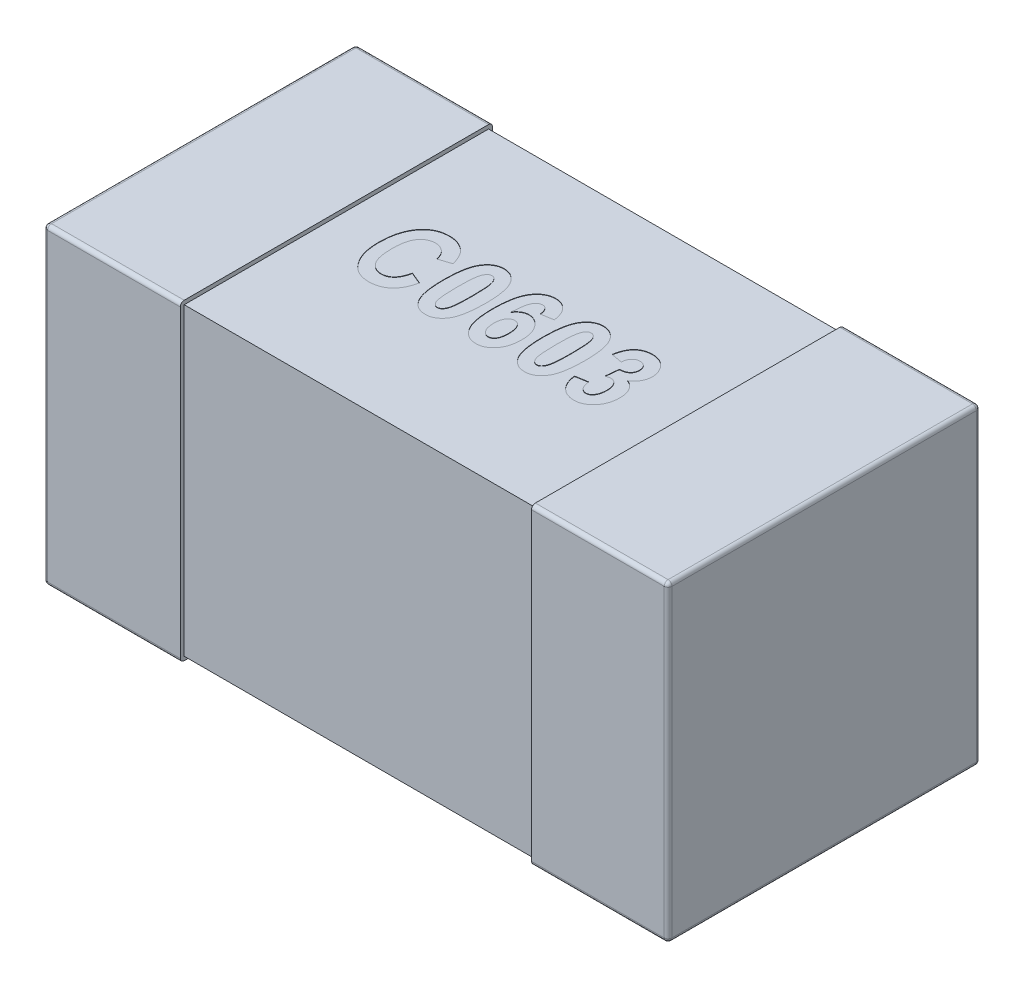
from build123d import *

# Parameters (mm, degrees)
SKETCH1_W            = 0.35
SKETCH1_H            = 0.8
THICKNESS_DEPTH      = 0.8
FILLET1_R            = 0.01
SKETCH2_W            = 0.78
SKETCH2_H            = 0.78
BOSS_EXTRUDE2_DEPTH  = 0.45
FILLET1_OF_MIRROR3_R = 0.01
CUT_EXTRUDE1_DEPTH   = 0.001


with BuildPart() as part:
    # Sketch1 → THICKNESS (new body)
    with BuildSketch(Plane(origin=(0, 0, 0), x_dir=(1, 0, 0), z_dir=(0, 1, 0))):
        with Locations((-0.625, 0)):
            Rectangle(SKETCH1_W, SKETCH1_H)
    thickness = extrude(amount=THICKNESS_DEPTH)

    # Fillet1
    fillet1_edges = [part.edges().sort_by_distance(p)[0] for p in [
        (-0.625, 0.8, -0.4),
        (-0.8, 0.8, 0),
        (-0.625, 0, -0.4),
        (-0.625, 0, 0.4),
        (-0.8, 0, 0),
        (-0.625, 0.8, 0.4),
        (-0.8, 0.4, -0.4),
        (-0.8, 0.4, 0.4),
    ]]
    fillet(fillet1_edges, radius=FILLET1_R)

    # Sketch2 → Boss-Extrude2 (add)
    with BuildSketch(Plane(origin=(0, 0, 0), x_dir=(0, 0, -1), z_dir=(1, 0, 0))):
        with Locations((0, 0.4)):
            Rectangle(SKETCH2_W, SKETCH2_H)
    boss_extrude2 = extrude(amount=-BOSS_EXTRUDE2_DEPTH)

    # Mirror3: THICKNESS, Boss-Extrude2 across plane
    add(thickness.mirror(Plane(origin=(0, 0, 0), x_dir=(0, 0, 1), z_dir=(1, 0, 0))))
    add(boss_extrude2.mirror(Plane(origin=(0, 0, 0), x_dir=(0, 0, 1), z_dir=(1, 0, 0))))

    # Fillet1 of Mirror3
    fillet1_of_mirror3_edges = [part.edges().sort_by_distance(p)[0] for p in [
        (0.625, 0.8, -0.4),
        (0.8, 0.8, 0),
        (0.625, 0, -0.4),
        (0.625, 0, 0.4),
        (0.8, 0, 0),
        (0.625, 0.8, 0.4),
        (0.8, 0.4, -0.4),
        (0.8, 0.4, 0.4),
    ]]
    fillet(fillet1_of_mirror3_edges, radius=FILLET1_OF_MIRROR3_R)

    # Sketch3 → Cut-Extrude1 (cut)
    with BuildSketch(Plane(origin=(0, 0.79, 0), x_dir=(1, 0, 0), z_dir=(0, 1, 0))):
        with BuildLine():
            Line((-0.227922078, -0.027272727), (-0.196753247, -0.04025974))
            add(Edge.make_bspline(
                [(-0.196753247, -0.04025974), (-0.197396972, -0.042879768), (-0.198651302, -0.04798502), (-0.201024323, -0.055281862), (-0.20363556, -0.062052219), (-0.206622963, -0.068258196), (-0.209884108, -0.07395424), (-0.213506576, -0.0790843), (-0.217422215, -0.083674642), (-0.221653294, -0.087714541), (-0.226192954, -0.09119055), (-0.230913731, -0.094288028), (-0.23593753, -0.0968273), (-0.241194004, -0.098971324), (-0.246724478, -0.10056505), (-0.252486934, -0.101764395), (-0.258506105, -0.102450716), (-0.262606545, -0.102547957), (-0.264691558, -0.102597403)],
                knots=[0, 0, 0, 0, 8.091e-06, 1.5766e-05, 2.3002e-05, 2.9845e-05, 3.6409e-05, 4.267e-05, 4.8657e-05, 5.4484e-05, 6.0183e-05, 6.5789e-05, 7.1397e-05, 7.7042e-05, 8.2795e-05, 8.8638e-05, 9.4684e-05, 0.000100938, 0.000100938, 0.000100938, 0.000100938], degree=3))
            add(Edge.make_bspline(
                [(-0.264691558, -0.102597403), (-0.267307616, -0.102538587), (-0.27243241, -0.102423369), (-0.27991047, -0.101183652), (-0.287026489, -0.099300118), (-0.293767638, -0.096595352), (-0.300141913, -0.093138085), (-0.306081973, -0.088855751), (-0.311726426, -0.083907776), (-0.315008286, -0.080049813), (-0.316680195, -0.078084416)],
                knots=[0, 0, 0, 0, 7.841e-06, 1.5361e-05, 2.2676e-05, 2.9888e-05, 3.7098e-05, 4.4373e-05, 5.1818e-05, 5.955e-05, 5.955e-05, 5.955e-05, 5.955e-05], degree=3))
            add(Edge.make_bspline(
                [(-0.316680195, -0.078084416), (-0.318517958, -0.075657886), (-0.322220302, -0.070769417), (-0.32686839, -0.062708341), (-0.330821677, -0.054048069), (-0.334057248, -0.044780752), (-0.336579205, -0.034896124), (-0.338342381, -0.024389471), (-0.339401221, -0.013265876), (-0.33953961, -0.005643601), (-0.33961039, -0.00174513)],
                knots=[0, 0, 0, 0, 9.125e-06, 1.8382e-05, 2.7844e-05, 3.765e-05, 4.7789e-05, 5.8411e-05, 6.9581e-05, 8.1275e-05, 8.1275e-05, 8.1275e-05, 8.1275e-05], degree=3))
            add(Edge.make_bspline(
                [(-0.33961039, -0.00174513), (-0.339545727, 0.002370257), (-0.339419775, 0.010386341), (-0.338285771, 0.022056996), (-0.336557029, 0.033059647), (-0.333979548, 0.043353397), (-0.330750684, 0.052997355), (-0.326761432, 0.061931382), (-0.322129511, 0.070248915), (-0.318350392, 0.075216426), (-0.316477273, 0.077678571)],
                knots=[0, 0, 0, 0, 1.2343e-05, 2.4042e-05, 3.5145e-05, 4.5726e-05, 5.5839e-05, 6.5614e-05, 7.5047e-05, 8.4318e-05, 8.4318e-05, 8.4318e-05, 8.4318e-05], degree=3))
            add(Edge.make_bspline(
                [(-0.316477273, 0.077678571), (-0.314776573, 0.079668828), (-0.311424858, 0.083591197), (-0.305695981, 0.088670389), (-0.299541368, 0.092987883), (-0.292963246, 0.096522814), (-0.285932181, 0.099272168), (-0.278482585, 0.101212155), (-0.27058463, 0.102356825), (-0.265182368, 0.102515984), (-0.262418831, 0.102597403)],
                knots=[0, 0, 0, 0, 7.846e-06, 1.5463e-05, 2.2894e-05, 3.0357e-05, 3.7811e-05, 4.5489e-05, 5.3404e-05, 6.1693e-05, 6.1693e-05, 6.1693e-05, 6.1693e-05], degree=3))
            add(Edge.make_bspline(
                [(-0.262418831, 0.102597403), (-0.26015725, 0.102543269), (-0.255712218, 0.102436871), (-0.249194385, 0.10158628), (-0.242984546, 0.100090634), (-0.237022085, 0.098128813), (-0.231359313, 0.095503917), (-0.225979856, 0.092318759), (-0.220862559, 0.088583811), (-0.217760884, 0.085680237), (-0.216193182, 0.084212662)],
                knots=[0, 0, 0, 0, 6.784e-06, 1.3333e-05, 1.9672e-05, 2.5922e-05, 3.2133e-05, 3.8355e-05, 4.4654e-05, 5.1092e-05, 5.1092e-05, 5.1092e-05, 5.1092e-05], degree=3))
            add(Edge.make_bspline(
                [(-0.216193182, 0.084212662), (-0.215103174, 0.083081576), (-0.212882044, 0.080776741), (-0.209891288, 0.076894389), (-0.207122366, 0.072618732), (-0.204624923, 0.067931521), (-0.20230313, 0.062878571), (-0.200191884, 0.057433978), (-0.198334576, 0.051585357), (-0.1972885, 0.04752972), (-0.196753247, 0.045454545)],
                knots=[0, 0, 0, 0, 4.71e-06, 9.597e-06, 1.4674e-05, 1.9976e-05, 2.5515e-05, 3.1348e-05, 3.7483e-05, 4.3912e-05, 4.3912e-05, 4.3912e-05, 4.3912e-05], degree=3))
            Line((-0.196753247, 0.045454545), (-0.227922078, 0.035064935))
            add(Edge.make_bspline(
                [(-0.227922078, 0.035064935), (-0.22821497, 0.03639518), (-0.228784889, 0.038983617), (-0.229929141, 0.042719083), (-0.231322222, 0.046188588), (-0.232837913, 0.049475424), (-0.234663056, 0.052465903), (-0.236572214, 0.055302912), (-0.238810881, 0.057816392), (-0.24117597, 0.060138417), (-0.243750905, 0.062145031), (-0.246386582, 0.0639597), (-0.249161582, 0.065468465), (-0.252064328, 0.066681891), (-0.255060441, 0.06766392), (-0.258172246, 0.068354506), (-0.261392621, 0.068772702), (-0.263580975, 0.068811486), (-0.264691558, 0.068831169)],
                knots=[0, 0, 0, 0, 4.085e-06, 7.949e-06, 1.1703e-05, 1.5297e-05, 1.8791e-05, 2.2202e-05, 2.5539e-05, 2.8868e-05, 3.2133e-05, 3.5318e-05, 3.846e-05, 4.1588e-05, 4.4745e-05, 4.7906e-05, 5.1138e-05, 5.4468e-05, 5.4468e-05, 5.4468e-05, 5.4468e-05], degree=3))
            add(Edge.make_bspline(
                [(-0.264691558, 0.068831169), (-0.26626331, 0.068784568), (-0.269356679, 0.068692853), (-0.27388873, 0.067963151), (-0.278176666, 0.066672511), (-0.282285043, 0.064978155), (-0.286144826, 0.062720768), (-0.289798982, 0.05998704), (-0.293149256, 0.056694357), (-0.296360139, 0.052990654), (-0.299269743, 0.048699448), (-0.301740196, 0.043739955), (-0.303777871, 0.038129881), (-0.305533087, 0.03190946), (-0.306846312, 0.025037823), (-0.30775765, 0.017525613), (-0.308326427, 0.009383722), (-0.308402299, 0.003734743), (-0.308441558, 0.000811688)],
                knots=[0, 0, 0, 0, 4.714e-06, 9.278e-06, 1.3721e-05, 1.8123e-05, 2.2578e-05, 2.7099e-05, 3.1778e-05, 3.6642e-05, 4.1786e-05, 4.7285e-05, 5.3218e-05, 5.9668e-05, 6.6656e-05, 7.4182e-05, 8.2359e-05, 9.1128e-05, 9.1128e-05, 9.1128e-05, 9.1128e-05], degree=3))
            add(Edge.make_bspline(
                [(-0.308441558, 0.000811688), (-0.308397197, -0.002219174), (-0.30831177, -0.008055698), (-0.307813801, -0.016485594), (-0.306867279, -0.024230738), (-0.30565566, -0.031321584), (-0.303997672, -0.037716685), (-0.30197212, -0.043419958), (-0.299639006, -0.048487083), (-0.296855851, -0.052851577), (-0.29377206, -0.056619436), (-0.290493427, -0.059890757), (-0.286956653, -0.062623492), (-0.283256357, -0.064939468), (-0.27929095, -0.066694454), (-0.275107345, -0.067888506), (-0.270730354, -0.068714375), (-0.267725822, -0.068791716), (-0.266193182, -0.068831169)],
                knots=[0, 0, 0, 0, 9.093e-06, 1.7511e-05, 2.5318e-05, 3.2491e-05, 3.9077e-05, 4.511e-05, 5.0629e-05, 5.5774e-05, 6.0592e-05, 6.5212e-05, 6.9636e-05, 7.3973e-05, 7.8279e-05, 8.2594e-05, 8.7004e-05, 9.1597e-05, 9.1597e-05, 9.1597e-05, 9.1597e-05], degree=3))
            add(Edge.make_bspline(
                [(-0.266193182, -0.068831169), (-0.265069119, -0.068796356), (-0.262839294, -0.068727297), (-0.259558087, -0.068287549), (-0.256391777, -0.067501289), (-0.253339938, -0.066410441), (-0.250415575, -0.064971207), (-0.247588686, -0.063266133), (-0.244916377, -0.061216615), (-0.242329307, -0.058889489), (-0.239889233, -0.056212882), (-0.237659193, -0.053135538), (-0.235587233, -0.049712456), (-0.23368588, -0.045922409), (-0.231943007, -0.041789753), (-0.230406306, -0.037282778), (-0.229015734, -0.032423983), (-0.228293652, -0.029022886), (-0.227922078, -0.027272727)],
                knots=[0, 0, 0, 0, 3.372e-06, 6.69e-06, 9.909e-06, 1.3144e-05, 1.6393e-05, 1.9671e-05, 2.3031e-05, 2.6479e-05, 3.0099e-05, 3.3874e-05, 3.7862e-05, 4.2091e-05, 4.6584e-05, 5.1307e-05, 5.6369e-05, 6.1735e-05, 6.1735e-05, 6.1735e-05, 6.1735e-05], degree=3))
        make_face()
        with BuildLine():
            add(Edge.make_bspline(
                [(-0.120211039, 0.1), (-0.118271666, 0.099928717), (-0.114444862, 0.09978806), (-0.10886145, 0.098706692), (-0.10354606, 0.096949861), (-0.098535416, 0.094457586), (-0.093826456, 0.091247567), (-0.08940735, 0.087339383), (-0.085274635, 0.082734709), (-0.081401732, 0.077392218), (-0.077921413, 0.071143907), (-0.074948986, 0.063877332), (-0.072452638, 0.055567403), (-0.070418476, 0.04621513), (-0.068804837, 0.035807223), (-0.06771206, 0.02434273), (-0.067016319, 0.011832198), (-0.066928681, 0.003139532), (-0.066883117, -0.00137987)],
                knots=[0, 0, 0, 0, 5.815e-06, 1.1474e-05, 1.6993e-05, 2.2565e-05, 2.8204e-05, 3.4042e-05, 4.022e-05, 4.6731e-05, 5.3799e-05, 6.1622e-05, 7.0236e-05, 7.9798e-05, 9.0313e-05, 0.000101814, 0.000114333, 0.000127891, 0.000127891, 0.000127891, 0.000127891], degree=3))
            add(Edge.make_bspline(
                [(-0.066883117, -0.00137987), (-0.06692878, -0.005885726), (-0.0670166, -0.014551317), (-0.067710789, -0.027021602), (-0.068809703, -0.038457937), (-0.070410234, -0.048841666), (-0.072468809, -0.058187167), (-0.074929964, -0.066495329), (-0.077933481, -0.073749514), (-0.081397979, -0.079992354), (-0.085278068, -0.085317136), (-0.089365782, -0.089949477), (-0.093787106, -0.093844803), (-0.098487071, -0.097042761), (-0.103473218, -0.099558417), (-0.108756542, -0.101289915), (-0.114307736, -0.102393362), (-0.118108863, -0.102528459), (-0.120048701, -0.102597403)],
                knots=[0, 0, 0, 0, 1.3517e-05, 2.5995e-05, 3.7456e-05, 4.7972e-05, 5.7493e-05, 6.6146e-05, 7.3932e-05, 8.1e-05, 8.7511e-05, 9.3662e-05, 9.9499e-05, 0.000105139, 0.000110675, 0.000116193, 0.000121773, 0.000127588, 0.000127588, 0.000127588, 0.000127588], degree=3))
            add(Edge.make_bspline(
                [(-0.120048701, -0.102597403), (-0.121987248, -0.102521566), (-0.125809946, -0.102372021), (-0.131402835, -0.101357073), (-0.136714376, -0.099586306), (-0.141712476, -0.097091823), (-0.146433618, -0.093930357), (-0.150850467, -0.090059007), (-0.154988758, -0.085498751), (-0.158134846, -0.081158842), (-0.160500485, -0.077321971), (-0.162150745, -0.07411272), (-0.163688856, -0.070636985), (-0.165169358, -0.066914403), (-0.166437987, -0.062872146), (-0.167661837, -0.058586872), (-0.168760463, -0.05402421), (-0.169708418, -0.0491983), (-0.170635402, -0.044119324), (-0.171324442, -0.038750083), (-0.172006233, -0.033127251), (-0.172458641, -0.02720805), (-0.172882219, -0.021040319), (-0.173143169, -0.014584752), (-0.173377504, -0.007875049), (-0.17337692, -0.003301099), (-0.173376623, -0.000974026)],
                knots=[0, 0, 0, 0, 5.815e-06, 1.1467e-05, 1.6986e-05, 2.2558e-05, 2.8174e-05, 3.3985e-05, 4.0133e-05, 4.6611e-05, 5.0036e-05, 5.3648e-05, 5.7427e-05, 6.1436e-05, 6.5658e-05, 7.0129e-05, 7.4805e-05, 7.9732e-05, 8.4883e-05, 9.029e-05, 9.5968e-05, 0.000101873, 0.000108096, 0.000114514, 0.000121254, 0.000128235, 0.000128235, 0.000128235, 0.000128235], degree=3))
            add(Edge.make_bspline(
                [(-0.173376623, -0.000974026), (-0.173331092, 0.003518327), (-0.173243538, 0.012156929), (-0.172547835, 0.024586386), (-0.171455601, 0.035969888), (-0.169838869, 0.046309974), (-0.167799473, 0.055619334), (-0.165321328, 0.06390888), (-0.162327065, 0.071152349), (-0.158861572, 0.077394895), (-0.154981718, 0.082719747), (-0.150893947, 0.087352071), (-0.146472637, 0.091247401), (-0.141772668, 0.094445358), (-0.136786522, 0.096961014), (-0.131503199, 0.098692512), (-0.125952004, 0.09979596), (-0.122150878, 0.099931056), (-0.120211039, 0.1)],
                knots=[0, 0, 0, 0, 1.3476e-05, 2.5914e-05, 3.7335e-05, 4.777e-05, 5.7292e-05, 6.5906e-05, 7.3692e-05, 8.076e-05, 8.727e-05, 9.3421e-05, 9.9259e-05, 0.000104898, 0.000110434, 0.000115953, 0.000121532, 0.000127347, 0.000127347, 0.000127347, 0.000127347], degree=3))
        make_face()
        with BuildLine():
            add(Edge.make_bspline(
                [(-0.12012987, 0.068831169), (-0.120850658, 0.06878971), (-0.122287512, 0.068707065), (-0.124377071, 0.068114283), (-0.126365328, 0.067171145), (-0.128214574, 0.065798414), (-0.129911973, 0.064014304), (-0.131541958, 0.061898335), (-0.133040682, 0.059389362), (-0.134479705, 0.056425788), (-0.135702567, 0.052704344), (-0.136779467, 0.048063201), (-0.137626629, 0.042374091), (-0.138335497, 0.035643009), (-0.138951313, 0.027876408), (-0.139324338, 0.019050672), (-0.139571299, 0.009187048), (-0.139596927, 0.002259382), (-0.13961039, -0.00137987)],
                knots=[0, 0, 0, 0, 2.161e-06, 4.307e-06, 6.467e-06, 8.732e-06, 1.1171e-05, 1.3834e-05, 1.6729e-05, 1.9924e-05, 2.3697e-05, 2.8452e-05, 3.4204e-05, 4.094e-05, 4.8756e-05, 5.7572e-05, 6.7437e-05, 7.8354e-05, 7.8354e-05, 7.8354e-05, 7.8354e-05], degree=3))
            add(Edge.make_bspline(
                [(-0.13961039, -0.00137987), (-0.13959717, -0.005019133), (-0.139572053, -0.011933295), (-0.139322751, -0.021783266), (-0.138954386, -0.03058231), (-0.138329205, -0.038348009), (-0.137634062, -0.045067106), (-0.136775554, -0.050754972), (-0.135700243, -0.055381735), (-0.134490697, -0.059096081), (-0.133030403, -0.06203629), (-0.131540484, -0.064534296), (-0.12992614, -0.066652952), (-0.128200364, -0.068395218), (-0.12636692, -0.069770124), (-0.124376658, -0.070711277), (-0.122287616, -0.071304571), (-0.120850692, -0.071387147), (-0.12012987, -0.071428571)],
                knots=[0, 0, 0, 0, 1.0918e-05, 2.0742e-05, 2.9558e-05, 3.7334e-05, 4.411e-05, 4.9822e-05, 5.4576e-05, 5.8349e-05, 6.1508e-05, 6.4403e-05, 6.7066e-05, 6.9476e-05, 7.1741e-05, 7.3901e-05, 7.6048e-05, 7.8208e-05, 7.8208e-05, 7.8208e-05, 7.8208e-05], degree=3))
            add(Edge.make_bspline(
                [(-0.12012987, -0.071428571), (-0.119395544, -0.071388007), (-0.117945093, -0.071307884), (-0.115840627, -0.070713563), (-0.113849527, -0.069756345), (-0.111964357, -0.068412424), (-0.1102841, -0.066611082), (-0.108616817, -0.064545629), (-0.107189663, -0.062011788), (-0.105737114, -0.059066347), (-0.104506396, -0.055346963), (-0.103507525, -0.050690529), (-0.102571884, -0.045018107), (-0.101881318, -0.038294951), (-0.101320907, -0.030539734), (-0.100932068, -0.021742987), (-0.100689475, -0.011906146), (-0.100663171, -0.005005573), (-0.100649351, -0.00137987)],
                knots=[0, 0, 0, 0, 2.201e-06, 4.347e-06, 6.507e-06, 8.805e-06, 1.1245e-05, 1.3875e-05, 1.675e-05, 1.9944e-05, 2.3718e-05, 2.8463e-05, 3.4221e-05, 4.0957e-05, 4.873e-05, 5.7546e-05, 6.737e-05, 7.8247e-05, 7.8247e-05, 7.8247e-05, 7.8247e-05], degree=3))
            add(Edge.make_bspline(
                [(-0.100649351, -0.00137987), (-0.10066328, 0.002259355), (-0.100689796, 0.009186969), (-0.100930798, 0.019050939), (-0.101322936, 0.027874546), (-0.101879144, 0.035643585), (-0.102572016, 0.042380138), (-0.103507605, 0.048052456), (-0.104506086, 0.05270922), (-0.105737976, 0.056427693), (-0.107187081, 0.059375797), (-0.108630427, 0.061910523), (-0.110270492, 0.064010732), (-0.11196588, 0.065813839), (-0.113849155, 0.067159231), (-0.115840722, 0.068116086), (-0.117945069, 0.068710501), (-0.119395535, 0.068790611), (-0.12012987, 0.068831169)],
                knots=[0, 0, 0, 0, 1.0918e-05, 2.0783e-05, 2.9599e-05, 3.7412e-05, 4.4148e-05, 4.9906e-05, 5.4651e-05, 5.8424e-05, 6.1619e-05, 6.4494e-05, 6.7156e-05, 6.9596e-05, 7.1893e-05, 7.4054e-05, 7.62e-05, 7.8401e-05, 7.8401e-05, 7.8401e-05, 7.8401e-05], degree=3))
        make_face(mode=Mode.SUBTRACT)
        with BuildLine():
            Line((0.057792208, 0.050649351), (0.026623377, 0.045454545))
            add(Edge.make_bspline(
                [(0.026623377, 0.045454545), (0.026418277, 0.047286661), (0.026032009, 0.050737124), (0.024908413, 0.055526606), (0.023377594, 0.0595879), (0.021485605, 0.062978473), (0.019086203, 0.065615575), (0.016255251, 0.067489325), (0.013005102, 0.068651121), (0.010697247, 0.06876956), (0.009496753, 0.068831169)],
                knots=[0, 0, 0, 0, 5.527e-06, 1.041e-05, 1.4714e-05, 1.8514e-05, 2.199e-05, 2.5299e-05, 2.861e-05, 3.22e-05, 3.22e-05, 3.22e-05, 3.22e-05], degree=3))
            add(Edge.make_bspline(
                [(0.009496753, 0.068831169), (0.008695165, 0.068805253), (0.007114303, 0.068754142), (0.004807941, 0.068185186), (0.002585635, 0.067334963), (0.000462231, 0.066103502), (-0.00152947, 0.064499634), (-0.003401666, 0.062561749), (-0.005200898, 0.060319074), (-0.00689616, 0.057665527), (-0.008464912, 0.054480114), (-0.009812741, 0.050615625), (-0.011060292, 0.046074168), (-0.012143152, 0.040812863), (-0.013050629, 0.034835656), (-0.013861545, 0.02815081), (-0.014505781, 0.020760056), (-0.01478787, 0.01559893), (-0.014935065, 0.012905844)],
                knots=[0, 0, 0, 0, 2.4e-06, 4.733e-06, 7.085e-06, 9.521e-06, 1.2063e-05, 1.4732e-05, 1.759e-05, 2.0675e-05, 2.416e-05, 2.8217e-05, 3.2933e-05, 3.8282e-05, 4.432e-05, 5.1066e-05, 5.8481e-05, 6.6571e-05, 6.6571e-05, 6.6571e-05, 6.6571e-05], degree=3))
            add(Edge.make_bspline(
                [(-0.014935065, 0.012905844), (-0.013973031, 0.014251331), (-0.012108086, 0.016859618), (-0.008976626, 0.020330313), (-0.005652775, 0.02323878), (-0.002196709, 0.025664338), (0.001457212, 0.027558657), (0.00530441, 0.028918636), (0.009357977, 0.029689288), (0.012118105, 0.029809372), (0.01351461, 0.02987013)],
                knots=[0, 0, 0, 0, 4.959e-06, 9.614e-06, 1.3986e-05, 1.8185e-05, 2.2251e-05, 2.6294e-05, 3.0385e-05, 3.4575e-05, 3.4575e-05, 3.4575e-05, 3.4575e-05], degree=3))
            add(Edge.make_bspline(
                [(0.01351461, 0.02987013), (0.015059707, 0.029811077), (0.018130591, 0.02969371), (0.022660526, 0.028888507), (0.027004273, 0.027420316), (0.03122194, 0.025465184), (0.035276457, 0.022937092), (0.039181837, 0.019846637), (0.042894629, 0.016177373), (0.046444725, 0.012015162), (0.049746076, 0.007415956), (0.052560367, 0.002356493), (0.055018523, -0.003021426), (0.057023128, -0.008777348), (0.058487412, -0.014917491), (0.059581566, -0.02141136), (0.060300349, -0.028257713), (0.060359447, -0.032952695), (0.06038961, -0.035349026)],
                knots=[0, 0, 0, 0, 4.635e-06, 9.213e-06, 1.3743e-05, 1.8355e-05, 2.313e-05, 2.8042e-05, 3.3266e-05, 3.8764e-05, 4.4439e-05, 5.0218e-05, 5.6103e-05, 6.2161e-05, 6.8471e-05, 7.5016e-05, 8.1909e-05, 8.9096e-05, 8.9096e-05, 8.9096e-05, 8.9096e-05], degree=3))
            add(Edge.make_bspline(
                [(0.06038961, -0.035349026), (0.060342852, -0.037907544), (0.060251878, -0.042885418), (0.059548408, -0.0501262), (0.058436966, -0.056943962), (0.056806506, -0.063335432), (0.054737909, -0.069326124), (0.052235528, -0.074918135), (0.049217365, -0.080055254), (0.045764368, -0.084713436), (0.041994209, -0.088894915), (0.037978302, -0.092563528), (0.033736649, -0.095673784), (0.029276794, -0.098221526), (0.024574252, -0.100188667), (0.019634763, -0.101547187), (0.014493931, -0.102443272), (0.010988649, -0.102545571), (0.009212662, -0.102597403)],
                knots=[0, 0, 0, 0, 7.674e-06, 1.4931e-05, 2.1803e-05, 2.8379e-05, 3.4693e-05, 4.0796e-05, 4.6727e-05, 5.253e-05, 5.8162e-05, 6.3592e-05, 6.882e-05, 7.3909e-05, 7.8967e-05, 8.4068e-05, 8.9252e-05, 9.4576e-05, 9.4576e-05, 9.4576e-05, 9.4576e-05], degree=3))
            add(Edge.make_bspline(
                [(0.009212662, -0.102597403), (0.007258951, -0.102530369), (0.003401148, -0.102398005), (-0.002229601, -0.101250901), (-0.007627556, -0.099477928), (-0.012718477, -0.096865203), (-0.017606703, -0.093597667), (-0.022184529, -0.08954328), (-0.026506004, -0.084782554), (-0.030599048, -0.079314794), (-0.034325719, -0.072988856), (-0.037453931, -0.065674637), (-0.040176417, -0.057465756), (-0.042316529, -0.048274435), (-0.044068513, -0.038168854), (-0.045240572, -0.027092521), (-0.045978418, -0.015080498), (-0.046061063, -0.006751724), (-0.046103896, -0.002435065)],
                knots=[0, 0, 0, 0, 5.856e-06, 1.1562e-05, 1.7171e-05, 2.2852e-05, 2.8671e-05, 3.4768e-05, 4.1146e-05, 4.7931e-05, 5.5226e-05, 6.3113e-05, 7.175e-05, 8.1141e-05, 9.1396e-05, 0.000102502, 0.000114537, 0.000127486, 0.000127486, 0.000127486, 0.000127486], degree=3))
            add(Edge.make_bspline(
                [(-0.046103896, -0.002435065), (-0.046063305, 0.001949215), (-0.045984937, 0.010413952), (-0.045215622, 0.022632457), (-0.043930453, 0.033903958), (-0.042172775, 0.044209666), (-0.039929635, 0.053587967), (-0.037100411, 0.061995026), (-0.033795093, 0.069478678), (-0.02995992, 0.076014918), (-0.025645912, 0.081613912), (-0.021139168, 0.086554502), (-0.016290119, 0.090735575), (-0.011111731, 0.094120819), (-0.005653013, 0.096755157), (9.1033e-05, 0.098628663), (0.006134045, 0.09980937), (0.010275923, 0.099935818), (0.012378247, 0.1)],
                knots=[0, 0, 0, 0, 1.3152e-05, 2.5392e-05, 3.6708e-05, 4.717e-05, 5.6738e-05, 6.5606e-05, 7.3745e-05, 8.1241e-05, 8.8279e-05, 9.4913e-05, 0.000101274, 0.000107431, 0.000113421, 0.000119402, 0.000125515, 0.000131816, 0.000131816, 0.000131816, 0.000131816], degree=3))
            add(Edge.make_bspline(
                [(0.012378247, 0.1), (0.013827679, 0.099959322), (0.016683654, 0.099879171), (0.020868675, 0.099296958), (0.024885162, 0.098371962), (0.028723853, 0.097024749), (0.032384973, 0.095261917), (0.035885717, 0.093152843), (0.039204025, 0.090650295), (0.042319373, 0.087759089), (0.045265466, 0.084514923), (0.047905907, 0.080832636), (0.050256031, 0.076761574), (0.052320972, 0.072298658), (0.054167357, 0.067468639), (0.055630193, 0.062199907), (0.056910771, 0.056569465), (0.057493401, 0.052656268), (0.057792208, 0.050649351)],
                knots=[0, 0, 0, 0, 4.347e-06, 8.566e-06, 1.2651e-05, 1.6694e-05, 2.0743e-05, 2.4821e-05, 2.8936e-05, 3.3187e-05, 3.7555e-05, 4.2061e-05, 4.6753e-05, 5.1636e-05, 5.68e-05, 6.2246e-05, 6.8026e-05, 7.4111e-05, 7.4111e-05, 7.4111e-05, 7.4111e-05], degree=3))
        make_face()
        with BuildLine():
            add(Edge.make_bspline(
                [(-0.012337662, -0.034090909), (-0.012308211, -0.035552337), (-0.012250889, -0.038396714), (-0.011982356, -0.042545039), (-0.011477045, -0.046428913), (-0.010668988, -0.050035663), (-0.009775233, -0.053386738), (-0.008631038, -0.056476674), (-0.007243652, -0.059283468), (-0.005678434, -0.061823635), (-0.003963137, -0.064067612), (-0.002173808, -0.06601145), (-0.000358522, -0.067713691), (0.001565205, -0.069030647), (0.003494403, -0.070149944), (0.005537037, -0.070853251), (0.007621826, -0.071328103), (0.009034202, -0.071395086), (0.00974026, -0.071428571)],
                knots=[0, 0, 0, 0, 4.385e-06, 8.534e-06, 1.2466e-05, 1.612e-05, 1.9615e-05, 2.2864e-05, 2.5986e-05, 2.8993e-05, 3.1801e-05, 3.4444e-05, 3.6915e-05, 3.9246e-05, 4.1425e-05, 4.3582e-05, 4.5699e-05, 4.7816e-05, 4.7816e-05, 4.7816e-05, 4.7816e-05], degree=3))
            add(Edge.make_bspline(
                [(0.00974026, -0.071428571), (0.011095086, -0.071343226), (0.013771917, -0.071174604), (0.017550686, -0.069553508), (0.020918722, -0.066973623), (0.023343989, -0.064089855), (0.025035494, -0.061284231), (0.026177405, -0.058796801), (0.027079585, -0.055965166), (0.027904028, -0.052856522), (0.028508247, -0.049421789), (0.02887811, -0.045676735), (0.029194544, -0.041617754), (0.029211819, -0.038799426), (0.029220779, -0.037337662)],
                knots=[0, 0, 0, 0, 4.047e-06, 7.996e-06, 1.2112e-05, 1.669e-05, 1.9203e-05, 2.1927e-05, 2.4878e-05, 2.8107e-05, 3.157e-05, 3.5326e-05, 3.9394e-05, 4.3778e-05, 4.3778e-05, 4.3778e-05, 4.3778e-05], degree=3))
            add(Edge.make_bspline(
                [(0.029220779, -0.037337662), (0.029209095, -0.035822095), (0.029186538, -0.032896255), (0.02890513, -0.02866819), (0.028413664, -0.024768664), (0.027780924, -0.021170587), (0.026935967, -0.017901105), (0.025919985, -0.01493598), (0.024718753, -0.012283036), (0.022859636, -0.009293535), (0.020278642, -0.006141345), (0.016653043, -0.003344448), (0.012608063, -0.00157765), (0.009757385, -0.001392215), (0.008319805, -0.001298701)],
                knots=[0, 0, 0, 0, 4.546e-06, 8.777e-06, 1.2703e-05, 1.6333e-05, 1.9729e-05, 2.2822e-05, 2.5728e-05, 2.8442e-05, 3.3368e-05, 3.7857e-05, 4.2078e-05, 4.6372e-05, 4.6372e-05, 4.6372e-05, 4.6372e-05], degree=3))
            add(Edge.make_bspline(
                [(0.008319805, -0.001298701), (0.006925228, -0.001401221), (0.00414295, -0.001605755), (0.000181679, -0.003247534), (-0.003398746, -0.00590863), (-0.005963885, -0.008903038), (-0.007815438, -0.011734191), (-0.009033568, -0.014188477), (-0.010033957, -0.016888825), (-0.01090374, -0.019826193), (-0.011523984, -0.023036601), (-0.012020061, -0.026488666), (-0.012303578, -0.030203571), (-0.012326034, -0.03276468), (-0.012337662, -0.034090909)],
                knots=[0, 0, 0, 0, 4.173e-06, 8.326e-06, 1.2652e-05, 1.7455e-05, 2.0067e-05, 2.2789e-05, 2.5653e-05, 2.8697e-05, 3.1969e-05, 3.5452e-05, 3.9157e-05, 4.3135e-05, 4.3135e-05, 4.3135e-05, 4.3135e-05], degree=3))
        make_face(mode=Mode.SUBTRACT)
        with BuildLine():
            add(Edge.make_bspline(
                [(0.134334416, 0.1), (0.136273789, 0.099928717), (0.140100592, 0.09978806), (0.145684005, 0.098706692), (0.150999395, 0.096949861), (0.156010039, 0.094457586), (0.160718998, 0.091247567), (0.165138104, 0.087339383), (0.16927082, 0.082734709), (0.173143723, 0.077392218), (0.176624041, 0.071143907), (0.179596468, 0.063877332), (0.182092817, 0.055567403), (0.184126978, 0.04621513), (0.185740617, 0.035807223), (0.186833394, 0.02434273), (0.187529136, 0.011832198), (0.187616774, 0.003139532), (0.187662338, -0.00137987)],
                knots=[0, 0, 0, 0, 5.815e-06, 1.1474e-05, 1.6993e-05, 2.2565e-05, 2.8204e-05, 3.4042e-05, 4.022e-05, 4.6731e-05, 5.3799e-05, 6.1622e-05, 7.0236e-05, 7.9798e-05, 9.0313e-05, 0.000101814, 0.000114333, 0.000127891, 0.000127891, 0.000127891, 0.000127891], degree=3))
            add(Edge.make_bspline(
                [(0.187662338, -0.00137987), (0.187616674, -0.005885726), (0.187528855, -0.014551317), (0.186834666, -0.027021602), (0.185735751, -0.038457937), (0.184135221, -0.048841666), (0.182076646, -0.058187167), (0.17961549, -0.066495329), (0.176611974, -0.073749514), (0.173147475, -0.079992354), (0.169267387, -0.085317136), (0.165179672, -0.089949477), (0.160758348, -0.093844803), (0.156058383, -0.097042761), (0.151072237, -0.099558417), (0.145788913, -0.101289915), (0.140237718, -0.102393362), (0.136436592, -0.102528459), (0.134496753, -0.102597403)],
                knots=[0, 0, 0, 0, 1.3517e-05, 2.5995e-05, 3.7456e-05, 4.7972e-05, 5.7493e-05, 6.6146e-05, 7.3932e-05, 8.1e-05, 8.7511e-05, 9.3662e-05, 9.9499e-05, 0.000105139, 0.000110675, 0.000116193, 0.000121773, 0.000127588, 0.000127588, 0.000127588, 0.000127588], degree=3))
            add(Edge.make_bspline(
                [(0.134496753, -0.102597403), (0.132558206, -0.102521566), (0.128735508, -0.102372021), (0.12314262, -0.101357073), (0.117831078, -0.099586306), (0.112832979, -0.097091823), (0.108111837, -0.093930357), (0.103694988, -0.090059007), (0.099556696, -0.085498751), (0.096410609, -0.081158842), (0.09404497, -0.077321971), (0.09239471, -0.07411272), (0.090856599, -0.070636985), (0.089376097, -0.066914403), (0.088107468, -0.062872146), (0.086883618, -0.058586872), (0.085784992, -0.05402421), (0.084837037, -0.0491983), (0.083910053, -0.044119324), (0.083221013, -0.038750083), (0.082539221, -0.033127251), (0.082086813, -0.02720805), (0.081663236, -0.021040319), (0.081402286, -0.014584752), (0.08116795, -0.007875049), (0.081168534, -0.003301099), (0.081168831, -0.000974026)],
                knots=[0, 0, 0, 0, 5.815e-06, 1.1467e-05, 1.6986e-05, 2.2558e-05, 2.8174e-05, 3.3985e-05, 4.0133e-05, 4.6611e-05, 5.0036e-05, 5.3648e-05, 5.7427e-05, 6.1436e-05, 6.5658e-05, 7.0129e-05, 7.4805e-05, 7.9732e-05, 8.4883e-05, 9.029e-05, 9.5968e-05, 0.000101873, 0.000108096, 0.000114514, 0.000121254, 0.000128235, 0.000128235, 0.000128235, 0.000128235], degree=3))
            add(Edge.make_bspline(
                [(0.081168831, -0.000974026), (0.081214362, 0.003518327), (0.081301917, 0.012156929), (0.081997619, 0.024586386), (0.083089854, 0.035969888), (0.084706586, 0.046309974), (0.086745981, 0.055619334), (0.089224126, 0.06390888), (0.09221839, 0.071152349), (0.095683883, 0.077394895), (0.099563736, 0.082719747), (0.103651508, 0.087352071), (0.108072818, 0.091247401), (0.112772786, 0.094445358), (0.117758932, 0.096961014), (0.123042256, 0.098692512), (0.128593451, 0.09979596), (0.132394577, 0.099931056), (0.134334416, 0.1)],
                knots=[0, 0, 0, 0, 1.3476e-05, 2.5914e-05, 3.7335e-05, 4.777e-05, 5.7292e-05, 6.5906e-05, 7.3692e-05, 8.076e-05, 8.727e-05, 9.3421e-05, 9.9259e-05, 0.000104898, 0.000110434, 0.000115953, 0.000121532, 0.000127347, 0.000127347, 0.000127347, 0.000127347], degree=3))
        make_face()
        with BuildLine():
            add(Edge.make_bspline(
                [(0.134415584, 0.068831169), (0.133694797, 0.06878971), (0.132257942, 0.068707065), (0.130168383, 0.068114283), (0.128180126, 0.067171145), (0.126330881, 0.065798414), (0.124633481, 0.064014304), (0.123003496, 0.061898335), (0.121504772, 0.059389362), (0.12006575, 0.056425788), (0.118842888, 0.052704344), (0.117765988, 0.048063201), (0.116918826, 0.042374091), (0.116209958, 0.035643009), (0.115594142, 0.027876408), (0.115221116, 0.019050672), (0.114974156, 0.009187048), (0.114948528, 0.002259382), (0.114935065, -0.00137987)],
                knots=[0, 0, 0, 0, 2.161e-06, 4.307e-06, 6.467e-06, 8.732e-06, 1.1171e-05, 1.3834e-05, 1.6729e-05, 1.9924e-05, 2.3697e-05, 2.8452e-05, 3.4204e-05, 4.094e-05, 4.8756e-05, 5.7572e-05, 6.7437e-05, 7.8354e-05, 7.8354e-05, 7.8354e-05, 7.8354e-05], degree=3))
            add(Edge.make_bspline(
                [(0.114935065, -0.00137987), (0.114948285, -0.005019133), (0.114973402, -0.011933295), (0.115222704, -0.021783266), (0.115591069, -0.03058231), (0.116216249, -0.038348009), (0.116911393, -0.045067106), (0.1177699, -0.050754972), (0.118845212, -0.055381735), (0.120054757, -0.059096081), (0.121515051, -0.06203629), (0.123004971, -0.064534296), (0.124619314, -0.066652952), (0.126345091, -0.068395218), (0.128178535, -0.069770124), (0.130168796, -0.070711277), (0.132257839, -0.071304571), (0.133694762, -0.071387147), (0.134415584, -0.071428571)],
                knots=[0, 0, 0, 0, 1.0918e-05, 2.0742e-05, 2.9558e-05, 3.7334e-05, 4.411e-05, 4.9822e-05, 5.4576e-05, 5.8349e-05, 6.1508e-05, 6.4403e-05, 6.7066e-05, 6.9476e-05, 7.1741e-05, 7.3901e-05, 7.6048e-05, 7.8208e-05, 7.8208e-05, 7.8208e-05, 7.8208e-05], degree=3))
            add(Edge.make_bspline(
                [(0.134415584, -0.071428571), (0.135149911, -0.071388007), (0.136600361, -0.071307884), (0.138704828, -0.070713563), (0.140695928, -0.069756345), (0.142581097, -0.068412424), (0.144261354, -0.066611082), (0.145928638, -0.064545629), (0.147355791, -0.062011788), (0.14880834, -0.059066347), (0.150039059, -0.055346963), (0.151037929, -0.050690529), (0.151973571, -0.045018107), (0.152664137, -0.038294951), (0.153224548, -0.030539734), (0.153613387, -0.021742987), (0.15385598, -0.011906146), (0.153882283, -0.005005573), (0.153896104, -0.00137987)],
                knots=[0, 0, 0, 0, 2.201e-06, 4.347e-06, 6.507e-06, 8.805e-06, 1.1245e-05, 1.3875e-05, 1.675e-05, 1.9944e-05, 2.3718e-05, 2.8463e-05, 3.4221e-05, 4.0957e-05, 4.873e-05, 5.7546e-05, 6.737e-05, 7.8247e-05, 7.8247e-05, 7.8247e-05, 7.8247e-05], degree=3))
            add(Edge.make_bspline(
                [(0.153896104, -0.00137987), (0.153882174, 0.002259355), (0.153855658, 0.009186969), (0.153614657, 0.019050939), (0.153222519, 0.027874546), (0.152666311, 0.035643585), (0.151973438, 0.042380138), (0.15103785, 0.048052456), (0.150039369, 0.05270922), (0.148807479, 0.056427693), (0.147358374, 0.059375797), (0.145915028, 0.061910523), (0.144274962, 0.064010732), (0.142579574, 0.065813839), (0.140696299, 0.067159231), (0.138704732, 0.068116086), (0.136600386, 0.068710501), (0.135149919, 0.068790611), (0.134415584, 0.068831169)],
                knots=[0, 0, 0, 0, 1.0918e-05, 2.0783e-05, 2.9599e-05, 3.7412e-05, 4.4148e-05, 4.9906e-05, 5.4651e-05, 5.8424e-05, 6.1619e-05, 6.4494e-05, 6.7156e-05, 6.9596e-05, 7.1893e-05, 7.4054e-05, 7.62e-05, 7.8401e-05, 7.8401e-05, 7.8401e-05, 7.8401e-05], degree=3))
        make_face(mode=Mode.SUBTRACT)
        with BuildLine():
            Line((0.208441558, -0.048051948), (0.23961039, -0.042857143))
            add(Edge.make_bspline(
                [(0.23961039, -0.042857143), (0.239839338, -0.045043993), (0.240273488, -0.049190869), (0.241736976, -0.054953381), (0.243753333, -0.059933194), (0.246380892, -0.064067508), (0.249488639, -0.067303152), (0.252865259, -0.06971071), (0.256582539, -0.071184449), (0.259173064, -0.071347095), (0.260470779, -0.071428571)],
                knots=[0, 0, 0, 0, 6.589e-06, 1.2495e-05, 1.7771e-05, 2.2646e-05, 2.7095e-05, 3.1148e-05, 3.5014e-05, 3.8896e-05, 3.8896e-05, 3.8896e-05, 3.8896e-05], degree=3))
            add(Edge.make_bspline(
                [(0.260470779, -0.071428571), (0.261881528, -0.071319102), (0.264696548, -0.071100666), (0.268682722, -0.069307445), (0.272255421, -0.066424481), (0.275399281, -0.062473467), (0.27802546, -0.057562016), (0.279861716, -0.05171563), (0.280998858, -0.045065932), (0.281110273, -0.04034597), (0.281168831, -0.03786526)],
                knots=[0, 0, 0, 0, 4.219e-06, 8.418e-06, 1.2867e-05, 1.7887e-05, 2.3462e-05, 2.9481e-05, 3.6193e-05, 4.3629e-05, 4.3629e-05, 4.3629e-05, 4.3629e-05], degree=3))
            add(Edge.make_bspline(
                [(0.281168831, -0.03786526), (0.281111601, -0.035546375), (0.281003045, -0.031147792), (0.27985156, -0.024942281), (0.278012041, -0.019494492), (0.27542225, -0.014890601), (0.272295537, -0.011184072), (0.268772776, -0.008458007), (0.264840019, -0.00679598), (0.262095722, -0.006594785), (0.260714286, -0.006493506)],
                knots=[0, 0, 0, 0, 6.95e-06, 1.3182e-05, 1.8855e-05, 2.4126e-05, 2.8933e-05, 3.3308e-05, 3.7385e-05, 4.1518e-05, 4.1518e-05, 4.1518e-05, 4.1518e-05], degree=3))
            add(Edge.make_bspline(
                [(0.260714286, -0.006493506), (0.259737382, -0.006520856), (0.25768691, -0.006578262), (0.254494199, -0.007230505), (0.251010665, -0.008088083), (0.248640624, -0.008933424), (0.247402597, -0.009375)],
                knots=[0, 0, 0, 0, 2.927e-06, 6.143e-06, 9.745e-06, 1.3685e-05, 1.3685e-05, 1.3685e-05, 1.3685e-05], degree=3))
            Line((0.247402597, -0.009375), (0.250811688, 0.024675325))
            add(Edge.make_bspline(
                [(0.250811688, 0.024675325), (0.252847195, 0.024704297), (0.256735618, 0.024759642), (0.26223412, 0.025875123), (0.267150632, 0.027732769), (0.269856006, 0.029737531), (0.271185065, 0.030722403)],
                knots=[0, 0, 0, 0, 6.094e-06, 1.1642e-05, 1.6759e-05, 2.1701e-05, 2.1701e-05, 2.1701e-05, 2.1701e-05], degree=3))
            add(Edge.make_bspline(
                [(0.271185065, 0.030722403), (0.272332891, 0.031819854), (0.274629722, 0.034015885), (0.276926059, 0.038315969), (0.278363298, 0.043183688), (0.278499979, 0.046647235), (0.278571429, 0.048457792)],
                knots=[0, 0, 0, 0, 4.737e-06, 9.479e-06, 1.4424e-05, 1.984e-05, 1.984e-05, 1.984e-05, 1.984e-05], degree=3))
            add(Edge.make_bspline(
                [(0.278571429, 0.048457792), (0.278517647, 0.04996543), (0.278414521, 0.052856341), (0.277398216, 0.056935846), (0.275659452, 0.060499557), (0.273228414, 0.063473738), (0.270305121, 0.065884465), (0.266933602, 0.06762901), (0.263170054, 0.068669544), (0.260531605, 0.068776208), (0.259172078, 0.068831169)],
                knots=[0, 0, 0, 0, 4.517e-06, 8.661e-06, 1.2508e-05, 1.6318e-05, 2.0096e-05, 2.3799e-05, 2.7629e-05, 3.17e-05, 3.17e-05, 3.17e-05, 3.17e-05], degree=3))
            add(Edge.make_bspline(
                [(0.259172078, 0.068831169), (0.257796199, 0.068756473), (0.255082705, 0.068609158), (0.25115823, 0.067320821), (0.247544574, 0.06521212), (0.244279748, 0.062286577), (0.241430375, 0.05858655), (0.239258508, 0.054037749), (0.2377025, 0.048719657), (0.237251336, 0.04488368), (0.237012987, 0.042857143)],
                knots=[0, 0, 0, 0, 4.119e-06, 8.124e-06, 1.2251e-05, 1.6592e-05, 2.1195e-05, 2.6168e-05, 3.1626e-05, 3.7739e-05, 3.7739e-05, 3.7739e-05, 3.7739e-05], degree=3))
            Line((0.237012987, 0.042857143), (0.208441558, 0.048051948))
            add(Edge.make_bspline(
                [(0.208441558, 0.048051948), (0.208851976, 0.050248144), (0.209649393, 0.054515222), (0.211180504, 0.060649), (0.213009121, 0.066317266), (0.215099188, 0.071526477), (0.217513205, 0.076251291), (0.220131138, 0.08054598), (0.223077869, 0.084349849), (0.226289392, 0.087698703), (0.229777256, 0.090579567), (0.233434718, 0.09313439), (0.237358701, 0.095230257), (0.241464845, 0.096997681), (0.245809328, 0.098330402), (0.250356022, 0.099308516), (0.25513978, 0.099878791), (0.258399464, 0.099959012), (0.260064935, 0.1)],
                knots=[0, 0, 0, 0, 6.702e-06, 1.3021e-05, 1.8951e-05, 2.4558e-05, 2.9839e-05, 3.4851e-05, 3.9624e-05, 4.4246e-05, 4.874e-05, 5.3176e-05, 5.7607e-05, 6.2062e-05, 6.6567e-05, 7.1216e-05, 7.5998e-05, 8.0994e-05, 8.0994e-05, 8.0994e-05, 8.0994e-05], degree=3))
            add(Edge.make_bspline(
                [(0.260064935, 0.1), (0.261920637, 0.099954901), (0.265552321, 0.099866641), (0.270844535, 0.099128602), (0.275828138, 0.097898052), (0.280543788, 0.096249906), (0.284949999, 0.094035303), (0.289057433, 0.091332711), (0.292926034, 0.088207326), (0.296352749, 0.08453521), (0.299488663, 0.080655665), (0.302228722, 0.076608179), (0.304553406, 0.072474266), (0.306432006, 0.068217314), (0.307904267, 0.06385726), (0.308947989, 0.059386056), (0.309635981, 0.05482379), (0.309705401, 0.0517476), (0.30974026, 0.050202922)],
                knots=[0, 0, 0, 0, 5.565e-06, 1.0892e-05, 1.5991e-05, 2.0945e-05, 2.5846e-05, 3.0743e-05, 3.5674e-05, 4.0726e-05, 4.5778e-05, 5.0629e-05, 5.5371e-05, 5.9986e-05, 6.4568e-05, 6.9156e-05, 7.3747e-05, 7.8378e-05, 7.8378e-05, 7.8378e-05, 7.8378e-05], degree=3))
            add(Edge.make_bspline(
                [(0.30974026, 0.050202922), (0.309673611, 0.048127931), (0.309542822, 0.044056094), (0.308405105, 0.038107933), (0.306584751, 0.032465705), (0.303995837, 0.027144692), (0.300691189, 0.022150846), (0.296583032, 0.017545853), (0.291853871, 0.013156497), (0.288224466, 0.01065668), (0.286363636, 0.009375)],
                knots=[0, 0, 0, 0, 6.22e-06, 1.2206e-05, 1.8097e-05, 2.396e-05, 2.9903e-05, 3.6e-05, 4.2435e-05, 4.9205e-05, 4.9205e-05, 4.9205e-05, 4.9205e-05], degree=3))
            add(Edge.make_bspline(
                [(0.286363636, 0.009375), (0.287400986, 0.009047174), (0.289478336, 0.008390684), (0.292419925, 0.006978492), (0.295249171, 0.005364759), (0.297898746, 0.003427469), (0.300423795, 0.001240483), (0.302769194, -0.001248535), (0.304989164, -0.003997406), (0.307028146, -0.007016672), (0.308913683, -0.01027195), (0.310530348, -0.01374915), (0.311855242, -0.017440851), (0.313020662, -0.02129149), (0.313836235, -0.025373778), (0.314508985, -0.029621282), (0.31486622, -0.034084766), (0.314911733, -0.03712066), (0.314935065, -0.038676948)],
                knots=[0, 0, 0, 0, 3.26e-06, 6.528e-06, 9.765e-06, 1.302e-05, 1.6357e-05, 1.9773e-05, 2.3266e-05, 2.6947e-05, 3.0692e-05, 3.4541e-05, 3.8431e-05, 4.2451e-05, 4.6598e-05, 5.0909e-05, 5.5347e-05, 6.0016e-05, 6.0016e-05, 6.0016e-05, 6.0016e-05], degree=3))
            add(Edge.make_bspline(
                [(0.314935065, -0.038676948), (0.314895664, -0.040938835), (0.314818506, -0.045368179), (0.313996818, -0.051849041), (0.312815407, -0.058051027), (0.311063694, -0.06396578), (0.30877713, -0.069563887), (0.306052966, -0.074894832), (0.302796274, -0.079895787), (0.299062371, -0.08452249), (0.295065668, -0.088772051), (0.290759423, -0.092442478), (0.28630996, -0.095594223), (0.281617079, -0.098137322), (0.276758115, -0.100124081), (0.271698353, -0.101565835), (0.266453452, -0.102436454), (0.262882063, -0.102543417), (0.261079545, -0.102597403)],
                knots=[0, 0, 0, 0, 6.782e-06, 1.3281e-05, 1.9569e-05, 2.5707e-05, 3.1751e-05, 3.7686e-05, 4.3641e-05, 4.9618e-05, 5.5503e-05, 6.1115e-05, 6.6565e-05, 7.1831e-05, 7.7092e-05, 8.2282e-05, 8.7586e-05, 9.2991e-05, 9.2991e-05, 9.2991e-05, 9.2991e-05], degree=3))
            add(Edge.make_bspline(
                [(0.261079545, -0.102597403), (0.259359196, -0.1025485), (0.255958717, -0.102451837), (0.250969855, -0.101749666), (0.246184834, -0.10061229), (0.241596692, -0.099020438), (0.23721509, -0.096952717), (0.233044785, -0.094396964), (0.229059284, -0.091443053), (0.225329597, -0.088021457), (0.221878253, -0.084214014), (0.218789342, -0.08002774), (0.216105902, -0.075490025), (0.213790883, -0.070639623), (0.211829479, -0.065472435), (0.210311485, -0.059964709), (0.209099932, -0.054138225), (0.208664545, -0.050113327), (0.208441558, -0.048051948)],
                knots=[0, 0, 0, 0, 5.16e-06, 1.0199e-05, 1.5082e-05, 1.9895e-05, 2.4742e-05, 2.9587e-05, 3.4546e-05, 3.9602e-05, 4.4745e-05, 4.994e-05, 5.5181e-05, 6.0536e-05, 6.6046e-05, 7.1738e-05, 7.766e-05, 8.3877e-05, 8.3877e-05, 8.3877e-05, 8.3877e-05], degree=3))
        make_face()
    extrude(amount=-CUT_EXTRUDE1_DEPTH, mode=Mode.SUBTRACT)


solid = part.part
